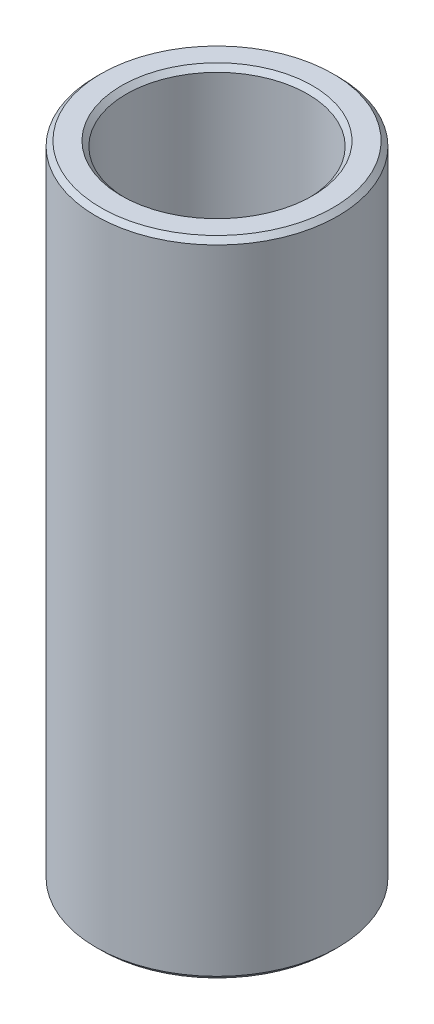
from build123d import *

# Parameters (mm, degrees)
SKETCH1_W     = 1.5875
SKETCH1_H     = 33.776182894
CHAMFER1_SIZE = 0.254


with BuildPart() as part:
    # Sketch1 → Revolve1 (revolve)
    with BuildSketch(Plane.XY):
        with Locations((5.55625, 148.650481377)):
            Rectangle(SKETCH1_W, SKETCH1_H)
    revolve(axis=Axis((0, 122.23738993, 0), (0, 1, 0)))

    # Chamfer1
    chamfer1_edges = [part.edges().sort_by_distance(p)[0] for p in [
        (-6.35, 131.76238993, 0),
        (-6.350000001, 165.538572824, 0),
        (-4.762500001, 165.538572824, 0),
        (-4.7625, 131.76238993, 0),
    ]]
    chamfer(chamfer1_edges, length=CHAMFER1_SIZE)


solid = part.part
